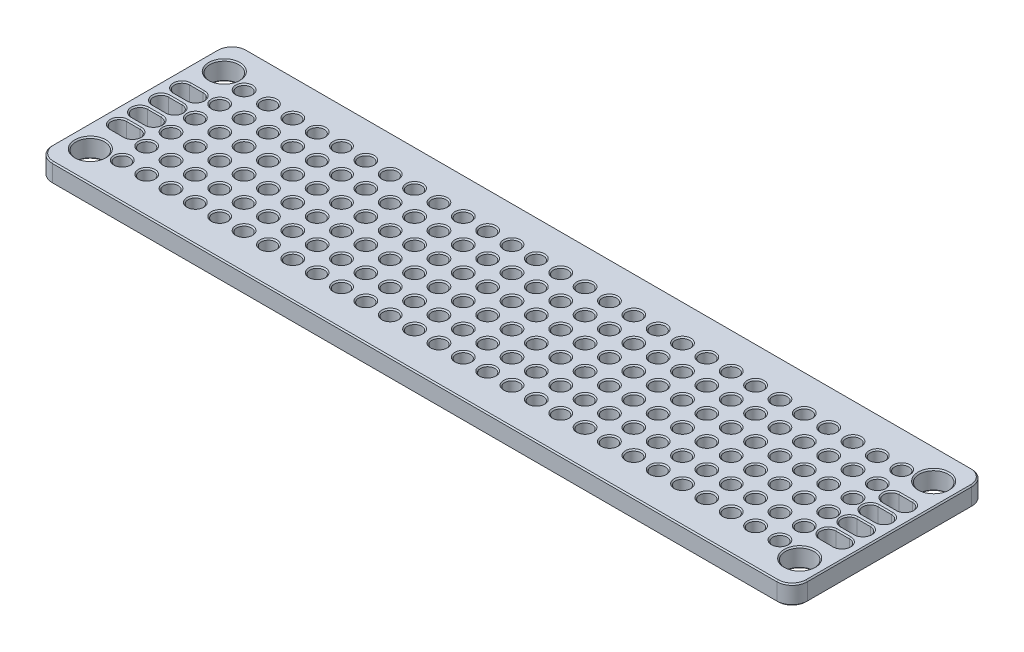
from build123d import *

# Parameters (mm, degrees)
SKETCH1_W               = 78.74
SKETCH1_H               = 20.32
BOSS_EXTRUDE1_DEPTH     = 0.99949
SKETCH2_R               = 1.5
CUT_EXTRUDE1_DEPTH      = 41.672121659
CUT_EXTRUDE1_DEPTH_BACK = 41.672121659
CUT_EXTRUDE2_DEPTH      = 41.672121659
CUT_EXTRUDE2_DEPTH_BACK = 41.672121659
SKETCH4_R               = 0.75057
CUT_EXTRUDE3_DEPTH      = 41.672121659
LPATTERN1_COUNT         = 28
LPATTERN1_PITCH         = 2.54
FILLET1_R               = 1.5875
CHAMFER1_SIZE           = 0.127


with BuildPart() as part:
    # Sketch1 → Boss-Extrude1 (new, symmetric)
    with BuildSketch(Plane(origin=(0, 0, 0), x_dir=(1, 0, 0), z_dir=(0, 1, 0))):
        Rectangle(SKETCH1_W, SKETCH1_H)
    extrude(amount=BOSS_EXTRUDE1_DEPTH, both=True)

    # Sketch2 → Cut-Extrude1 (cut, two sides)
    with BuildSketch(Plane(origin=(0, 0, 0), x_dir=(1, 0, 0), z_dir=(0, 1, 0))) as cut_extrude1_sk:
        with Locations(Location((-36.98875, 6.985, 0), (0, 0, 270))):
            Circle(SKETCH2_R)
        with Locations(Location((-36.98875, -6.985, 0), (0, 0, 270))):
            Circle(SKETCH2_R)
        with Locations(Location((36.98875, -6.985, 0), (0, 0, 270))):
            Circle(SKETCH2_R)
        with Locations(Location((36.98875, 6.985, 0), (0, 0, 270))):
            Circle(SKETCH2_R)
    extrude(amount=CUT_EXTRUDE1_DEPTH, mode=Mode.SUBTRACT)
    extrude(cut_extrude1_sk.sketch, amount=-CUT_EXTRUDE1_DEPTH_BACK, mode=Mode.SUBTRACT)

    # Sketch3 → Cut-Extrude2 (cut, two sides)
    with BuildSketch(Plane(origin=(0, 0, 0), x_dir=(1, 0, 0), z_dir=(0, 1, 0))) as cut_extrude2_sk:
        with BuildLine():
            Line((-37.695, 4.08475), (-36.2825, 4.08475))
            ThreePointArc((-36.2825, 4.08475), (-35.48875, 3.291), (-36.2825, 2.49725))
            Line((-36.2825, 2.49725), (-37.695, 2.49725))
            ThreePointArc((-37.695, 2.49725), (-38.48875, 3.291), (-37.695, 4.08475))
        make_face()
        with BuildLine():
            Line((-37.695, 1.89075), (-36.2825, 1.89075))
            ThreePointArc((-36.2825, 1.89075), (-35.48875, 1.097), (-36.2825, 0.30325))
            Line((-36.2825, 0.30325), (-37.695, 0.30325))
            ThreePointArc((-37.695, 0.30325), (-38.48875, 1.097), (-37.695, 1.89075))
        make_face()
        with BuildLine():
            Line((-37.695, -0.30325), (-36.2825, -0.30325))
            ThreePointArc((-36.2825, -0.30325), (-35.48875, -1.097), (-36.2825, -1.89075))
            Line((-36.2825, -1.89075), (-37.695, -1.89075))
            ThreePointArc((-37.695, -1.89075), (-38.48875, -1.097), (-37.695, -0.30325))
        make_face()
        with BuildLine():
            Line((-37.695, -2.49725), (-36.2825, -2.49725))
            ThreePointArc((-36.2825, -2.49725), (-35.48875, -3.291), (-36.2825, -4.08475))
            Line((-36.2825, -4.08475), (-37.695, -4.08475))
            ThreePointArc((-37.695, -4.08475), (-38.48875, -3.291), (-37.695, -2.49725))
        make_face()
        with BuildLine():
            Line((37.695, -2.49725), (36.2825, -2.49725))
            ThreePointArc((36.2825, -2.49725), (35.48875, -3.291), (36.2825, -4.08475))
            Line((36.2825, -4.08475), (37.695, -4.08475))
            ThreePointArc((37.695, -4.08475), (38.48875, -3.291), (37.695, -2.49725))
        make_face()
        with BuildLine():
            Line((37.695, -0.30325), (36.2825, -0.30325))
            ThreePointArc((36.2825, -0.30325), (35.48875, -1.097), (36.2825, -1.89075))
            Line((36.2825, -1.89075), (37.695, -1.89075))
            ThreePointArc((37.695, -1.89075), (38.48875, -1.097), (37.695, -0.30325))
        make_face()
        with BuildLine():
            Line((37.695, 1.89075), (36.2825, 1.89075))
            ThreePointArc((36.2825, 1.89075), (35.48875, 1.097), (36.2825, 0.30325))
            Line((36.2825, 0.30325), (37.695, 0.30325))
            ThreePointArc((37.695, 0.30325), (38.48875, 1.097), (37.695, 1.89075))
        make_face()
        with BuildLine():
            Line((37.695, 4.08475), (36.2825, 4.08475))
            ThreePointArc((36.2825, 4.08475), (35.48875, 3.291), (36.2825, 2.49725))
            Line((36.2825, 2.49725), (37.695, 2.49725))
            ThreePointArc((37.695, 2.49725), (38.48875, 3.291), (37.695, 4.08475))
        make_face()
    extrude(amount=CUT_EXTRUDE2_DEPTH, mode=Mode.SUBTRACT)
    extrude(cut_extrude2_sk.sketch, amount=-CUT_EXTRUDE2_DEPTH_BACK, mode=Mode.SUBTRACT)

    # Sketch4 → Cut-Extrude3 (cut, symmetric)
    with BuildSketch(Plane(origin=(0, 0, 0), x_dir=(1, 0, 0), z_dir=(0, 1, 0))):
        with Locations(Location((-34.29, 6.35, 0), (0, 0, 270))):
            Circle(SKETCH4_R)
        with Locations(Location((-34.29, 3.81, 0), (0, 0, 270))):
            Circle(SKETCH4_R)
        with Locations(Location((-34.29, 1.27, 0), (0, 0, 270))):
            Circle(SKETCH4_R)
        with Locations(Location((-34.29, -1.27, 0), (0, 0, 270))):
            Circle(SKETCH4_R)
        with Locations(Location((-34.29, -3.81, 0), (0, 0, 270))):
            Circle(SKETCH4_R)
        with Locations(Location((-34.29, -6.35, 0), (0, 0, 270))):
            Circle(SKETCH4_R)
    cut_extrude3 = extrude(amount=CUT_EXTRUDE3_DEPTH, both=True, mode=Mode.SUBTRACT)

    # LPattern1: Cut-Extrude3 ×28
    with Locations(*[(i * LPATTERN1_PITCH, 0, 0) for i in range(1, LPATTERN1_COUNT)]):
        add(cut_extrude3, mode=Mode.SUBTRACT)

    # Fillet1
    fillet1_edges = [part.edges().sort_by_distance(p)[0] for p in [
        (-39.37, 0, 10.16),
        (39.37, 0, 10.16),
        (39.37, 0, -10.16),
        (-39.37, 0, -10.16),
    ]]
    fillet(fillet1_edges, radius=FILLET1_R)

    # Chamfer1
    chamfer1_edges = [part.edges().sort_by_distance(p)[0] for p in [
        (38.48875, -0.99949, -3.291),
        (36.98875, -0.99949, -2.49725),
        (35.48875, -0.99949, -3.291),
        (36.98875, -0.99949, -4.08475),
        (38.48875, 0.99949, -3.291),
        (36.98875, 0.99949, -4.08475),
        (35.48875, 0.99949, -3.291),
        (36.98875, 0.99949, -2.49725),
        (-38.48875, -0.99949, -3.291),
        (-36.98875, -0.99949, -4.08475),
        (-35.48875, -0.99949, -3.291),
        (-36.98875, -0.99949, -2.49725),
        (-38.48875, 0.99949, -3.291),
        (-36.98875, 0.99949, -2.49725),
        (-35.48875, 0.99949, -3.291),
        (-36.98875, 0.99949, -4.08475),
        (-34.29, -0.99949, -7.10057),
        (-34.29, 0.99949, -7.10057),
        (-34.29, -0.99949, -4.56057),
        (-34.29, 0.99949, -4.56057),
        (-34.29, -0.99949, -2.02057),
        (-34.29, 0.99949, -2.02057),
        (-34.29, -0.99949, 0.51943),
        (-34.29, 0.99949, 0.51943),
        (-34.29, -0.99949, 3.05943),
        (-34.29, 0.99949, 3.05943),
        (-34.29, -0.99949, 5.59943),
        (-34.29, 0.99949, 5.59943),
        (-31.75, 0.99949, -7.10057),
        (-31.75, -0.99949, -7.10057),
        (-29.21, -0.99949, -7.10057),
        (-29.21, 0.99949, -7.10057),
        (-26.67, -0.99949, -7.10057),
        (-26.67, 0.99949, -7.10057),
        (-24.13, -0.99949, -7.10057),
        (-24.13, 0.99949, -7.10057),
        (-21.59, -0.99949, -7.10057),
        (-21.59, 0.99949, -7.10057),
        (-19.05, -0.99949, -7.10057),
        (-19.05, 0.99949, -7.10057),
        (-16.51, -0.99949, -7.10057),
        (-16.51, 0.99949, -7.10057),
        (-13.97, -0.99949, -7.10057),
        (-13.97, 0.99949, -7.10057),
        (-11.43, -0.99949, -7.10057),
        (-11.43, 0.99949, -7.10057),
        (-8.89, -0.99949, -7.10057),
        (-8.89, 0.99949, -7.10057),
        (36.98875, -0.99949, -8.485),
        (-6.35, -0.99949, -7.10057),
        (-6.35, 0.99949, -7.10057),
        (-3.81, -0.99949, -7.10057),
        (-3.81, 0.99949, -7.10057),
        (36.98875, 0.99949, -8.485),
        (-1.27, -0.99949, -7.10057),
        (-1.27, 0.99949, -7.10057),
        (1.27, -0.99949, -7.10057),
        (1.27, 0.99949, -7.10057),
        (3.81, -0.99949, -7.10057),
        (3.81, 0.99949, -7.10057),
        (6.35, -0.99949, -7.10057),
        (6.35, 0.99949, -7.10057),
        (8.89, -0.99949, -7.10057),
        (8.89, 0.99949, -7.10057),
        (11.43, -0.99949, -7.10057),
        (11.43, 0.99949, -7.10057),
        (13.97, -0.99949, -7.10057),
        (13.97, 0.99949, -7.10057),
        (16.51, -0.99949, -7.10057),
        (16.51, 0.99949, -7.10057),
        (36.98875, -0.99949, 5.485),
        (19.05, -0.99949, -7.10057),
        (19.05, 0.99949, -7.10057),
        (21.59, -0.99949, -7.10057),
        (21.59, 0.99949, -7.10057),
        (36.98875, 0.99949, 5.485),
        (24.13, -0.99949, -7.10057),
        (24.13, 0.99949, -7.10057),
        (26.67, -0.99949, -7.10057),
        (26.67, 0.99949, -7.10057),
        (29.21, -0.99949, -7.10057),
        (29.21, 0.99949, -7.10057),
        (31.75, -0.99949, -7.10057),
        (31.75, 0.99949, -7.10057),
        (34.29, -0.99949, -7.10057),
        (34.29, 0.99949, -7.10057),
        (-36.98875, -0.99949, 5.485),
        (-31.75, 0.99949, 5.59943),
        (-31.75, -0.99949, 5.59943),
        (-36.98875, 0.99949, 5.485),
        (-29.21, -0.99949, 5.59943),
        (-29.21, 0.99949, 5.59943),
        (-26.67, -0.99949, 5.59943),
        (-26.67, 0.99949, 5.59943),
        (-24.13, -0.99949, 5.59943),
        (-24.13, 0.99949, 5.59943),
        (-21.59, -0.99949, 5.59943),
        (-21.59, 0.99949, 5.59943),
        (-19.05, -0.99949, 5.59943),
        (-19.05, 0.99949, 5.59943),
        (-16.51, -0.99949, 5.59943),
        (-16.51, 0.99949, 5.59943),
        (-13.97, -0.99949, 5.59943),
        (-13.97, 0.99949, 5.59943),
        (-11.43, -0.99949, 5.59943),
        (-11.43, 0.99949, 5.59943),
        (-8.89, -0.99949, 5.59943),
        (-36.98875, -0.99949, -8.485),
        (-8.89, 0.99949, 5.59943),
        (-6.35, -0.99949, 5.59943),
        (-6.35, 0.99949, 5.59943),
        (-36.98875, 0.99949, -8.485),
        (-3.81, -0.99949, 5.59943),
        (-3.81, 0.99949, 5.59943),
        (-1.27, -0.99949, 5.59943),
        (-1.27, 0.99949, 5.59943),
        (1.27, -0.99949, 5.59943),
        (1.27, 0.99949, 5.59943),
        (3.81, -0.99949, 5.59943),
        (3.81, 0.99949, 5.59943),
        (6.35, -0.99949, 5.59943),
        (6.35, 0.99949, 5.59943),
        (8.89, -0.99949, 5.59943),
        (8.89, 0.99949, 5.59943),
        (11.43, -0.99949, 5.59943),
        (11.43, 0.99949, 5.59943),
        (13.97, -0.99949, 5.59943),
        (13.97, 0.99949, 5.59943),
        (16.51, -0.99949, 5.59943),
        (16.51, 0.99949, 5.59943),
        (19.05, -0.99949, 5.59943),
        (19.05, 0.99949, 5.59943),
        (21.59, -0.99949, 5.59943),
        (21.59, 0.99949, 5.59943),
        (24.13, -0.99949, 5.59943),
        (24.13, 0.99949, 5.59943),
        (26.67, -0.99949, 5.59943),
        (26.67, 0.99949, 5.59943),
        (29.21, -0.99949, 5.59943),
        (29.21, 0.99949, 5.59943),
        (31.75, -0.99949, 5.59943),
        (31.75, 0.99949, 5.59943),
        (34.29, -0.99949, 5.59943),
        (34.29, 0.99949, 5.59943),
        (-31.75, 0.99949, 3.05943),
        (-31.75, -0.99949, 3.05943),
        (-29.21, -0.99949, 3.05943),
        (-29.21, 0.99949, 3.05943),
        (-26.67, -0.99949, 3.05943),
        (-26.67, 0.99949, 3.05943),
        (-24.13, -0.99949, 3.05943),
        (-24.13, 0.99949, 3.05943),
        (-21.59, -0.99949, 3.05943),
        (-21.59, 0.99949, 3.05943),
        (-19.05, -0.99949, 3.05943),
        (-19.05, 0.99949, 3.05943),
        (-16.51, -0.99949, 3.05943),
        (-16.51, 0.99949, 3.05943),
        (-13.97, -0.99949, 3.05943),
        (-13.97, 0.99949, 3.05943),
        (-11.43, -0.99949, 3.05943),
        (-11.43, 0.99949, 3.05943),
        (-8.89, -0.99949, 3.05943),
        (-8.89, 0.99949, 3.05943),
        (-6.35, -0.99949, 3.05943),
        (-6.35, 0.99949, 3.05943),
        (-3.81, -0.99949, 3.05943),
        (-3.81, 0.99949, 3.05943),
        (-1.27, -0.99949, 3.05943),
        (-1.27, 0.99949, 3.05943),
        (1.27, -0.99949, 3.05943),
        (1.27, 0.99949, 3.05943),
        (3.81, -0.99949, 3.05943),
        (3.81, 0.99949, 3.05943),
        (6.35, -0.99949, 3.05943),
        (6.35, 0.99949, 3.05943),
        (8.89, -0.99949, 3.05943),
        (8.89, 0.99949, 3.05943),
        (11.43, -0.99949, 3.05943),
        (11.43, 0.99949, 3.05943),
        (13.97, -0.99949, 3.05943),
        (13.97, 0.99949, 3.05943),
        (16.51, -0.99949, 3.05943),
        (16.51, 0.99949, 3.05943),
        (19.05, -0.99949, 3.05943),
        (19.05, 0.99949, 3.05943),
        (21.59, -0.99949, 3.05943),
        (21.59, 0.99949, 3.05943),
        (24.13, -0.99949, 3.05943),
        (24.13, 0.99949, 3.05943),
        (26.67, -0.99949, 3.05943),
        (26.67, 0.99949, 3.05943),
        (29.21, -0.99949, 3.05943),
        (29.21, 0.99949, 3.05943),
        (31.75, -0.99949, 3.05943),
        (31.75, 0.99949, 3.05943),
        (34.29, -0.99949, 3.05943),
        (34.29, 0.99949, 3.05943),
        (-31.75, 0.99949, 0.51943),
        (-31.75, -0.99949, 0.51943),
        (-29.21, -0.99949, 0.51943),
        (-29.21, 0.99949, 0.51943),
        (-26.67, -0.99949, 0.51943),
        (-26.67, 0.99949, 0.51943),
        (-24.13, -0.99949, 0.51943),
        (-24.13, 0.99949, 0.51943),
        (-21.59, -0.99949, 0.51943),
        (-21.59, 0.99949, 0.51943),
        (-19.05, -0.99949, 0.51943),
        (-19.05, 0.99949, 0.51943),
        (-16.51, -0.99949, 0.51943),
        (-16.51, 0.99949, 0.51943),
        (-13.97, -0.99949, 0.51943),
        (-13.97, 0.99949, 0.51943),
        (-11.43, -0.99949, 0.51943),
        (-11.43, 0.99949, 0.51943),
        (-8.89, -0.99949, 0.51943),
        (-8.89, 0.99949, 0.51943),
        (-6.35, -0.99949, 0.51943),
        (-6.35, 0.99949, 0.51943),
        (-3.81, -0.99949, 0.51943),
        (-3.81, 0.99949, 0.51943),
        (-1.27, -0.99949, 0.51943),
        (-1.27, 0.99949, 0.51943),
        (1.27, -0.99949, 0.51943),
        (1.27, 0.99949, 0.51943),
        (3.81, -0.99949, 0.51943),
        (3.81, 0.99949, 0.51943),
        (6.35, -0.99949, 0.51943),
        (6.35, 0.99949, 0.51943),
        (8.89, -0.99949, 0.51943),
        (8.89, 0.99949, 0.51943),
        (11.43, -0.99949, 0.51943),
        (11.43, 0.99949, 0.51943),
        (13.97, -0.99949, 0.51943),
        (13.97, 0.99949, 0.51943),
        (16.51, -0.99949, 0.51943),
        (16.51, 0.99949, 0.51943),
        (19.05, -0.99949, 0.51943),
        (19.05, 0.99949, 0.51943),
        (21.59, -0.99949, 0.51943),
        (21.59, 0.99949, 0.51943),
        (24.13, -0.99949, 0.51943),
        (24.13, 0.99949, 0.51943),
        (26.67, -0.99949, 0.51943),
        (26.67, 0.99949, 0.51943),
        (29.21, -0.99949, 0.51943),
        (29.21, 0.99949, 0.51943),
        (31.75, -0.99949, 0.51943),
        (31.75, 0.99949, 0.51943),
        (34.29, -0.99949, 0.51943),
        (34.29, 0.99949, 0.51943),
        (-31.75, 0.99949, -2.02057),
        (-31.75, -0.99949, -2.02057),
        (-29.21, -0.99949, -2.02057),
        (-29.21, 0.99949, -2.02057),
        (-26.67, -0.99949, -2.02057),
        (-26.67, 0.99949, -2.02057),
        (-24.13, -0.99949, -2.02057),
        (-24.13, 0.99949, -2.02057),
        (-21.59, -0.99949, -2.02057),
        (-21.59, 0.99949, -2.02057),
        (-19.05, -0.99949, -2.02057),
        (-19.05, 0.99949, -2.02057),
        (-16.51, -0.99949, -2.02057),
        (-16.51, 0.99949, -2.02057),
        (-13.97, -0.99949, -2.02057),
        (-13.97, 0.99949, -2.02057),
        (-11.43, -0.99949, -2.02057),
        (-11.43, 0.99949, -2.02057),
        (-8.89, -0.99949, -2.02057),
        (-8.89, 0.99949, -2.02057),
        (-6.35, -0.99949, -2.02057),
        (-6.35, 0.99949, -2.02057),
        (-3.81, -0.99949, -2.02057),
        (-3.81, 0.99949, -2.02057),
        (-1.27, -0.99949, -2.02057),
        (-1.27, 0.99949, -2.02057),
        (1.27, -0.99949, -2.02057),
        (1.27, 0.99949, -2.02057),
        (3.81, -0.99949, -2.02057),
        (3.81, 0.99949, -2.02057),
        (6.35, -0.99949, -2.02057),
        (6.35, 0.99949, -2.02057),
        (8.89, -0.99949, -2.02057),
        (8.89, 0.99949, -2.02057),
        (11.43, -0.99949, -2.02057),
        (11.43, 0.99949, -2.02057),
        (13.97, -0.99949, -2.02057),
        (13.97, 0.99949, -2.02057),
        (16.51, -0.99949, -2.02057),
        (16.51, 0.99949, -2.02057),
        (19.05, -0.99949, -2.02057),
        (19.05, 0.99949, -2.02057),
        (21.59, -0.99949, -2.02057),
        (21.59, 0.99949, -2.02057),
        (24.13, -0.99949, -2.02057),
        (24.13, 0.99949, -2.02057),
        (26.67, -0.99949, -2.02057),
        (26.67, 0.99949, -2.02057),
        (29.21, -0.99949, -2.02057),
        (29.21, 0.99949, -2.02057),
        (31.75, -0.99949, -2.02057),
        (31.75, 0.99949, -2.02057),
        (34.29, -0.99949, -2.02057),
        (34.29, 0.99949, -2.02057),
        (-31.75, 0.99949, -4.56057),
        (-31.75, -0.99949, -4.56057),
        (-29.21, -0.99949, -4.56057),
        (-29.21, 0.99949, -4.56057),
        (-26.67, -0.99949, -4.56057),
        (-26.67, 0.99949, -4.56057),
        (-24.13, -0.99949, -4.56057),
        (-24.13, 0.99949, -4.56057),
        (-21.59, -0.99949, -4.56057),
        (-21.59, 0.99949, -4.56057),
        (-19.05, -0.99949, -4.56057),
        (-19.05, 0.99949, -4.56057),
        (-16.51, -0.99949, -4.56057),
        (-16.51, 0.99949, -4.56057),
        (-13.97, -0.99949, -4.56057),
        (-13.97, 0.99949, -4.56057),
        (-11.43, -0.99949, -4.56057),
        (-11.43, 0.99949, -4.56057),
        (-8.89, -0.99949, -4.56057),
        (-8.89, 0.99949, -4.56057),
        (-6.35, -0.99949, -4.56057),
        (-6.35, 0.99949, -4.56057),
        (-3.81, -0.99949, -4.56057),
        (-3.81, 0.99949, -4.56057),
        (-1.27, -0.99949, -4.56057),
        (-1.27, 0.99949, -4.56057),
        (1.27, -0.99949, -4.56057),
        (1.27, 0.99949, -4.56057),
        (3.81, -0.99949, -4.56057),
        (3.81, 0.99949, -4.56057),
        (6.35, -0.99949, -4.56057),
        (6.35, 0.99949, -4.56057),
        (8.89, -0.99949, -4.56057),
        (8.89, 0.99949, -4.56057),
        (11.43, -0.99949, -4.56057),
        (11.43, 0.99949, -4.56057),
        (13.97, -0.99949, -4.56057),
        (13.97, 0.99949, -4.56057),
        (16.51, -0.99949, -4.56057),
        (16.51, 0.99949, -4.56057),
        (19.05, -0.99949, -4.56057),
        (19.05, 0.99949, -4.56057),
        (21.59, -0.99949, -4.56057),
        (21.59, 0.99949, -4.56057),
        (24.13, -0.99949, -4.56057),
        (24.13, 0.99949, -4.56057),
        (26.67, -0.99949, -4.56057),
        (26.67, 0.99949, -4.56057),
        (29.21, -0.99949, -4.56057),
        (29.21, 0.99949, -4.56057),
        (31.75, -0.99949, -4.56057),
        (31.75, 0.99949, -4.56057),
        (34.29, -0.99949, -4.56057),
        (34.29, 0.99949, -4.56057),
        (-39.37, -0.99949, 0),
        (-39.37, 0.99949, 0),
        (0, -0.99949, -10.16),
        (39.37, -0.99949, 0),
        (0, -0.99949, 10.16),
        (-38.905032015, -0.99949, 9.695032015),
        (38.905032015, -0.99949, 9.695032015),
        (38.905032015, -0.99949, -9.695032015),
        (-38.905032015, -0.99949, -9.695032015),
        (0, 0.99949, -10.16),
        (0, 0.99949, 10.16),
        (39.37, 0.99949, 0),
        (-38.905032015, 0.99949, 9.695032015),
        (38.905032015, 0.99949, 9.695032015),
        (38.905032015, 0.99949, -9.695032015),
        (-38.905032015, 0.99949, -9.695032015),
        (-38.48875, -0.99949, -1.097),
        (-36.98875, -0.99949, -1.89075),
        (-35.48875, -0.99949, -1.097),
        (-36.98875, -0.99949, -0.30325),
        (-38.48875, 0.99949, -1.097),
        (-36.98875, 0.99949, -0.30325),
        (-35.48875, 0.99949, -1.097),
        (-36.98875, 0.99949, -1.89075),
        (-38.48875, -0.99949, 1.097),
        (-36.98875, -0.99949, 0.30325),
        (-35.48875, -0.99949, 1.097),
        (-36.98875, -0.99949, 1.89075),
        (-38.48875, 0.99949, 1.097),
        (-36.98875, 0.99949, 1.89075),
        (-35.48875, 0.99949, 1.097),
        (-36.98875, 0.99949, 0.30325),
        (-38.48875, -0.99949, 3.291),
        (-36.98875, -0.99949, 2.49725),
        (-35.48875, -0.99949, 3.291),
        (-36.98875, -0.99949, 4.08475),
        (-38.48875, 0.99949, 3.291),
        (-36.98875, 0.99949, 4.08475),
        (-35.48875, 0.99949, 3.291),
        (-36.98875, 0.99949, 2.49725),
        (38.48875, -0.99949, 3.291),
        (36.98875, -0.99949, 4.08475),
        (35.48875, -0.99949, 3.291),
        (36.98875, -0.99949, 2.49725),
        (38.48875, 0.99949, 3.291),
        (36.98875, 0.99949, 2.49725),
        (35.48875, 0.99949, 3.291),
        (36.98875, 0.99949, 4.08475),
        (38.48875, -0.99949, 1.097),
        (36.98875, -0.99949, 1.89075),
        (35.48875, -0.99949, 1.097),
        (36.98875, -0.99949, 0.30325),
        (38.48875, 0.99949, 1.097),
        (36.98875, 0.99949, 0.30325),
        (35.48875, 0.99949, 1.097),
        (36.98875, 0.99949, 1.89075),
        (38.48875, -0.99949, -1.097),
        (36.98875, -0.99949, -0.30325),
        (35.48875, -0.99949, -1.097),
        (36.98875, -0.99949, -1.89075),
        (38.48875, 0.99949, -1.097),
        (36.98875, 0.99949, -1.89075),
        (35.48875, 0.99949, -1.097),
        (36.98875, 0.99949, -0.30325),
    ]]
    chamfer(chamfer1_edges, length=CHAMFER1_SIZE)


solid = part.part
